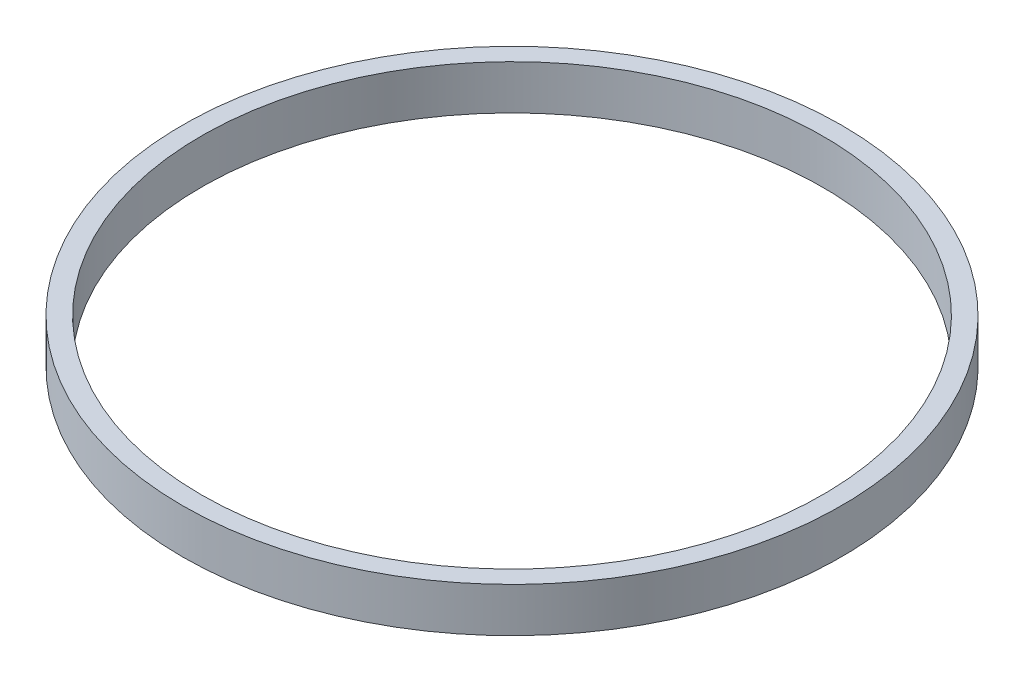
from build123d import *

# Parameters (mm, degrees)
SKETCH1_R      = 47.1424
SKETCH1_R_2    = 44.45
EXTRUDE1_DEPTH = 6.35


with BuildPart() as part:
    # Sketch1 → Extrude1 (new body)
    with BuildSketch(Plane(origin=(0, 0, 0), x_dir=(1, 0, 0), z_dir=(0, 1, 0))):
        Circle(SKETCH1_R)
        Circle(SKETCH1_R_2, mode=Mode.SUBTRACT)
    extrude(amount=-EXTRUDE1_DEPTH)


solid = part.part
